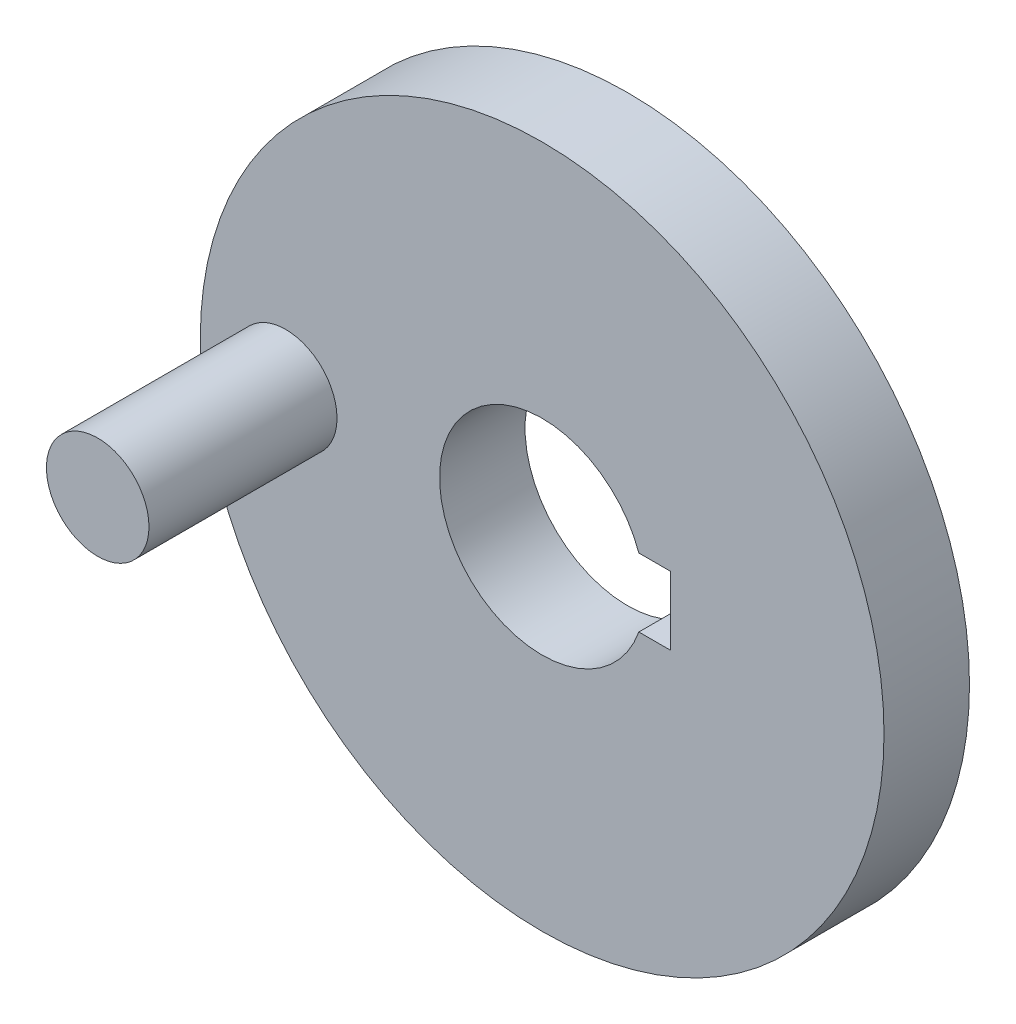
from build123d import *

# Parameters (mm, degrees)
SKETCH1_R           = 20
BOSS_EXTRUDE1_DEPTH = 5
SKETCH3_R           = 3
BOSS_EXTRUDE2_DEPTH = 11
CUT_EXTRUDE1_DEPTH  = 6


with BuildPart() as part:
    # Sketch1 → Boss-Extrude1 (new body)
    with BuildSketch(Plane.XY):
        Circle(SKETCH1_R)
    extrude(amount=BOSS_EXTRUDE1_DEPTH)

    # Sketch3 → Boss-Extrude2 (add)
    with BuildSketch(Plane.XY.offset(5)):
        with Locations((-15, 0)):
            Circle(SKETCH3_R)
    extrude(amount=BOSS_EXTRUDE2_DEPTH)

    # Sketch5 → Cut-Extrude1 (cut, through all)
    with BuildSketch(Plane.XY.offset(5)):
        with BuildLine():
            Line((5.656854249, 2), (7.5, 2))
            Line((7.5, 2), (7.5, -2))
            Line((7.5, -2), (5.656854249, -2))
            ThreePointArc((5.656854249, -2), (-6, 0), (5.656854249, 2))
        make_face()
    extrude(amount=-CUT_EXTRUDE1_DEPTH, mode=Mode.SUBTRACT)


solid = part.part
